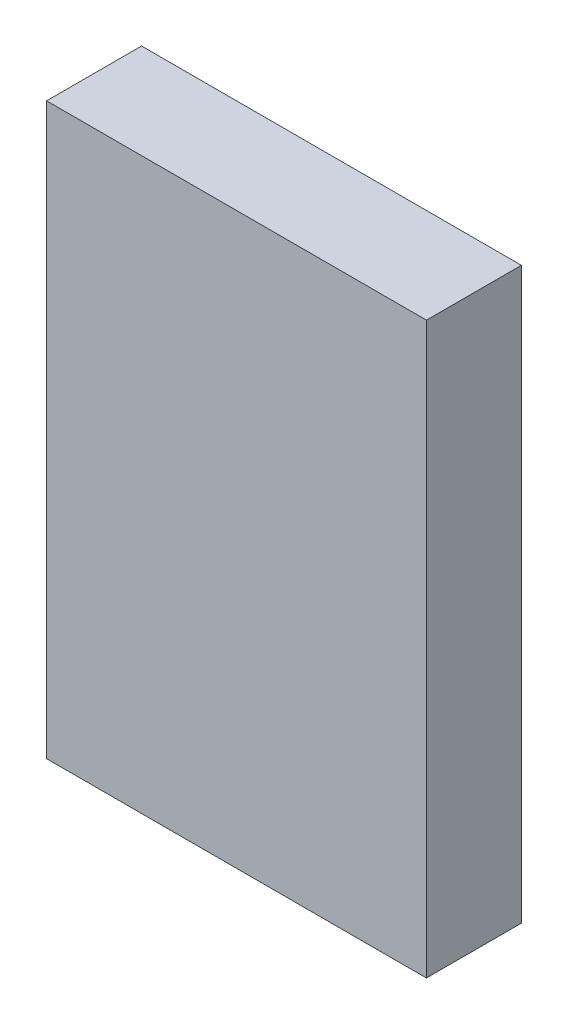
from build123d import *

# Parameters (mm, degrees)
SKETCH1_W           = 20
SKETCH1_H           = 30
BOSS_EXTRUDE1_DEPTH = 5


with BuildPart() as part:
    # Sketch1 → Boss-Extrude1 (new body)
    with BuildSketch(Plane.XY):
        with Locations((10, 15)):
            Rectangle(SKETCH1_W, SKETCH1_H)
    extrude(amount=BOSS_EXTRUDE1_DEPTH)


solid = part.part
